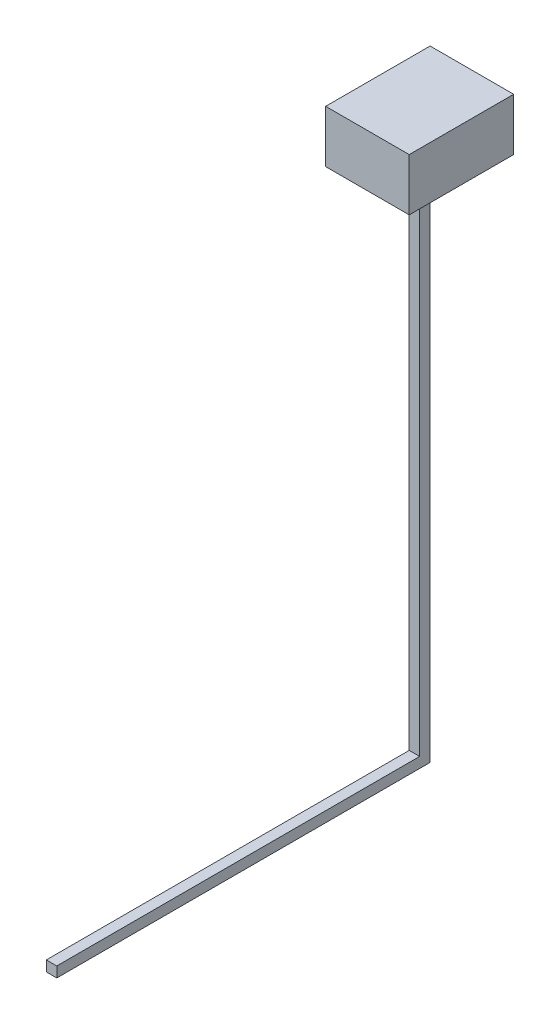
from build123d import *

# Parameters (mm, degrees)
EXTRUDE1_DEPTH = 10
SKETCH2_W      = 80
SKETCH2_H      = 100
EXTRUDE2_DEPTH = 50


with BuildPart() as part:
    # Sketch1 → Extrude1 (new body)
    with BuildSketch(Plane(origin=(0, 0, 0), x_dir=(0, 0, -1), z_dir=(1, 0, 0))):
        Polygon((0, 0), (357.360716499, 0), (357.360716499, 498.914273257), (347.360716499, 498.914273257), (347.360716499, 10), (0, 10), align=None)
    extrude(amount=EXTRUDE1_DEPTH)

    # Sketch2 → Extrude2 (add)
    with BuildSketch(Plane(origin=(0, 498.914273257, 0), x_dir=(-1, 0, 0), z_dir=(0, 1, 0))):
        with Locations((-5, -352.360716499)):
            Rectangle(SKETCH2_W, SKETCH2_H)
    extrude(amount=EXTRUDE2_DEPTH)


solid = part.part
